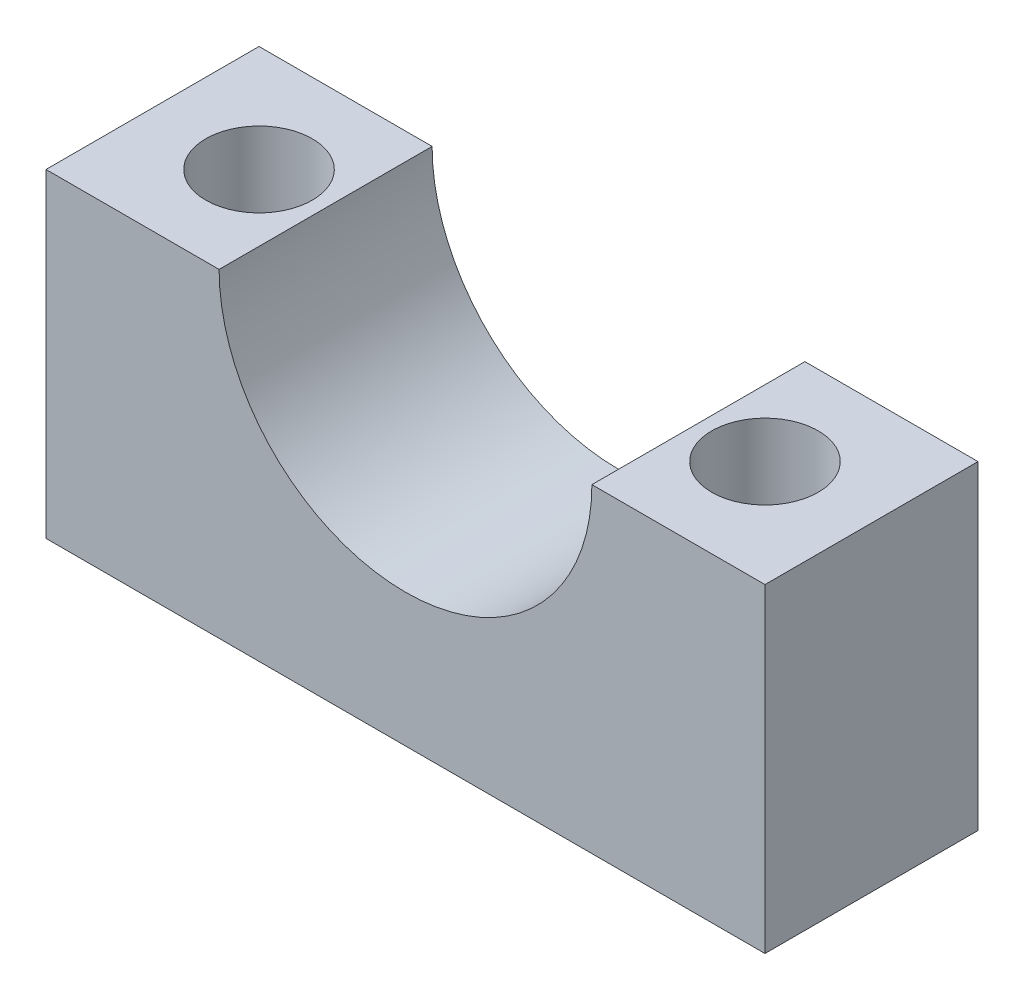
from build123d import *

# Parameters (mm, degrees)
BOSS_EXTRUDE1_DEPTH = 8
SKETCH2_R           = 2
CUT_EXTRUDE1_DEPTH  = 13


with BuildPart() as part:
    # Sketch1 → Boss-Extrude1 (new body)
    with BuildSketch(Plane.XY):
        with BuildLine():
            Line((-7.885993485, 10.084690554), (-7.885993485, -1.915309446))
            Line((-7.885993485, -1.915309446), (19.114006515, -1.915309446))
            Line((19.114006515, -1.915309446), (19.114006515, 10.084690554))
            Line((19.114006515, 10.084690554), (12.614006515, 10.084690554))
            ThreePointArc((12.614006515, 10.084690554), (5.614006515, 3.084690554), (-1.385993485, 10.084690554))
            Line((-1.385993485, 10.084690554), (-7.885993485, 10.084690554))
        make_face()
    extrude(amount=BOSS_EXTRUDE1_DEPTH)

    # Sketch2 → Cut-Extrude1 (cut, through all)
    with BuildSketch(Plane(origin=(0, 10.084690554, 0), x_dir=(1, 0, 0), z_dir=(0, 1, 0))):
        with Locations((-3.885993485, -4)):
            Circle(SKETCH2_R)
        with Locations((15.114006515, -4)):
            Circle(SKETCH2_R)
    extrude(amount=-CUT_EXTRUDE1_DEPTH, mode=Mode.SUBTRACT)


solid = part.part
